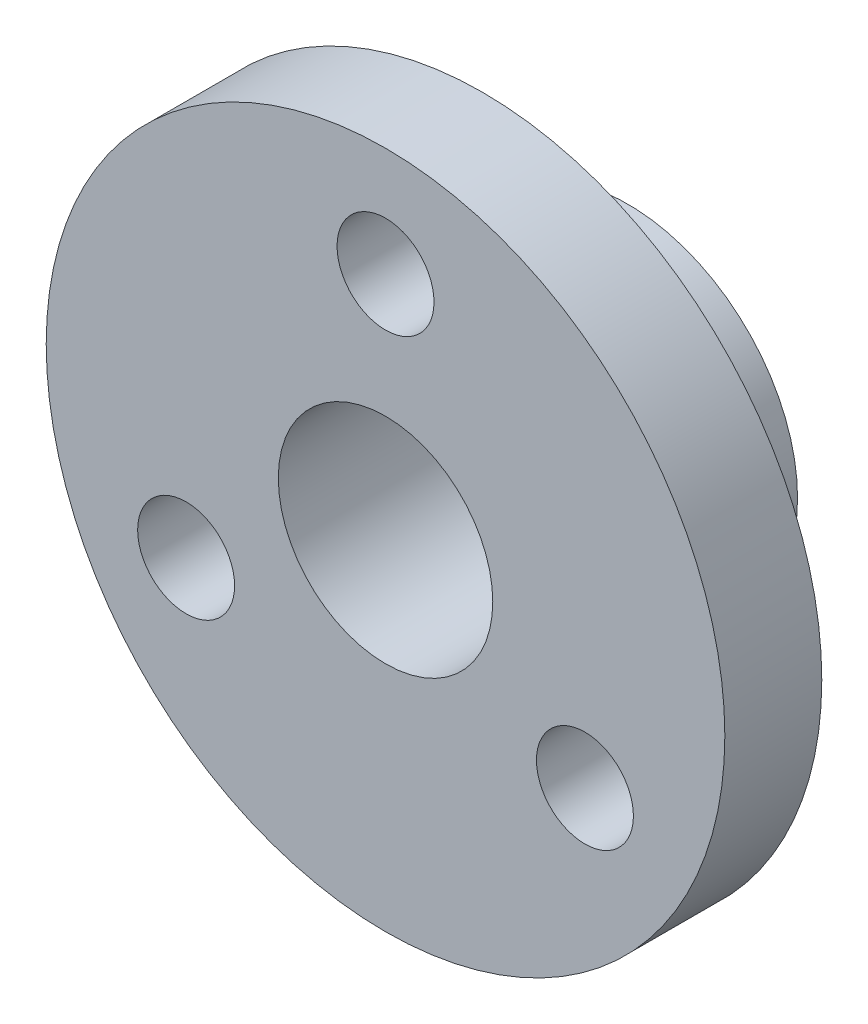
from build123d import *

# Parameters (mm, degrees)
IZIM1_R                     = 7
IZIM1_R_2                   = 2.212355073
Y_KSEKLIK_EKSTR_ZYON1_DEPTH = 2
IZIM2_R                     = 3.5
IZIM2_R_2                   = 2.212355073
Y_KSEKLIK_EKSTR_ZYON2_DEPTH = 5
IZIM3_R                     = 1
KES_EKSTR_ZYON1_DEPTH       = 5
SCALE1_SCALE                = 0.666666667


with BuildPart() as part:
    # Çizim1 → Yükseklik-Ekstrüzyon1 (new body)
    with BuildSketch(Plane.XY):
        with Locations((-30.711927379, -38.904760786)):
            Circle(IZIM1_R)
        with Locations((-30.711927379, -38.904760786)):
            Circle(IZIM1_R_2, mode=Mode.SUBTRACT)
    extrude(amount=Y_KSEKLIK_EKSTR_ZYON1_DEPTH)

    # Çizim2 → Yükseklik-Ekstrüzyon2 (add)
    with BuildSketch(Plane.XY.offset(2)):
        with Locations((-30.711927379, -38.904760786)):
            Circle(IZIM2_R)
        with Locations((-30.711927379, -38.904760786)):
            Circle(IZIM2_R_2, mode=Mode.SUBTRACT)
    extrude(amount=-Y_KSEKLIK_EKSTR_ZYON2_DEPTH)

    # Çizim3 → Kes-Ekstrüzyon1 (cut)
    with BuildSketch(Plane(origin=(0, 0, 0), x_dir=(-1, 0, 0), z_dir=(0, 0, -1))):
        with Locations((30.711927379, -34.154760786)):
            Circle(IZIM3_R)
        with Locations((34.825548047, -41.279760786)):
            Circle(IZIM3_R)
        with Locations((26.598306711, -41.279760786)):
            Circle(IZIM3_R)
    extrude(amount=-KES_EKSTR_ZYON1_DEPTH, mode=Mode.SUBTRACT)


with BuildPart() as part_1:
    # Scale1: scaled about (-30.711927379, -38.904760786, 0.470967588)
    add(part.part.scale(SCALE1_SCALE).moved(Location((-10.237309126, -12.968253595, 0.156989196))))


solid = part_1.part
